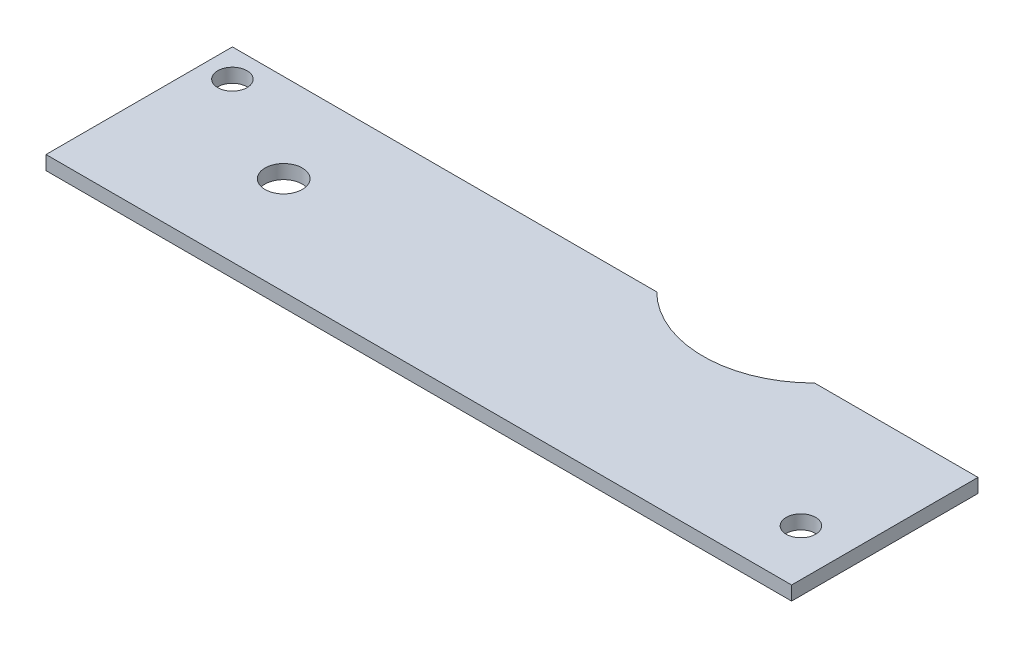
from build123d import *

# Parameters (mm, degrees)
SKETCH_1_R          = 2
EXTRUDE_1_DEPTH     = 1.5
HOLE_WIZARD_3_D     = 3.15
HOLE_WIZARD_3_DEPTH = 12
HOLE_WIZARD_3_TIP   = 0.946355475


with BuildPart() as part:
    # Эскиз1 → Бобышка-Вытянуть1 (new body)
    with BuildSketch(Plane(origin=(0, 0, 0), x_dir=(1, 0, 0), z_dir=(0, 1, 0))):
        with BuildLine():
            Line((0, 0), (80, 0))
            Line((80, 0), (80, 20))
            Line((80, 20), (62.470537173, 20))
            ThreePointArc((62.470537173, 20), (54, 16.5), (45.529462827, 20))
            Line((45.529462827, 20), (0, 20))
            Line((0, 20), (0, 0))
        make_face()
        with Locations((15, 10.5)):
            Circle(SKETCH_1_R, mode=Mode.SUBTRACT)
    extrude(amount=EXTRUDE_1_DEPTH)

    # Под_М3
    with Locations(Plane.XZ):
        with Locations((75, -6), (3, -17)):
            Hole(HOLE_WIZARD_3_D / 2, depth=HOLE_WIZARD_3_DEPTH)
            with Locations((0, 0, -(HOLE_WIZARD_3_DEPTH + HOLE_WIZARD_3_TIP / 2))):  # 118° drill point
                Cone(0, HOLE_WIZARD_3_D / 2, HOLE_WIZARD_3_TIP, mode=Mode.SUBTRACT)


solid = part.part
